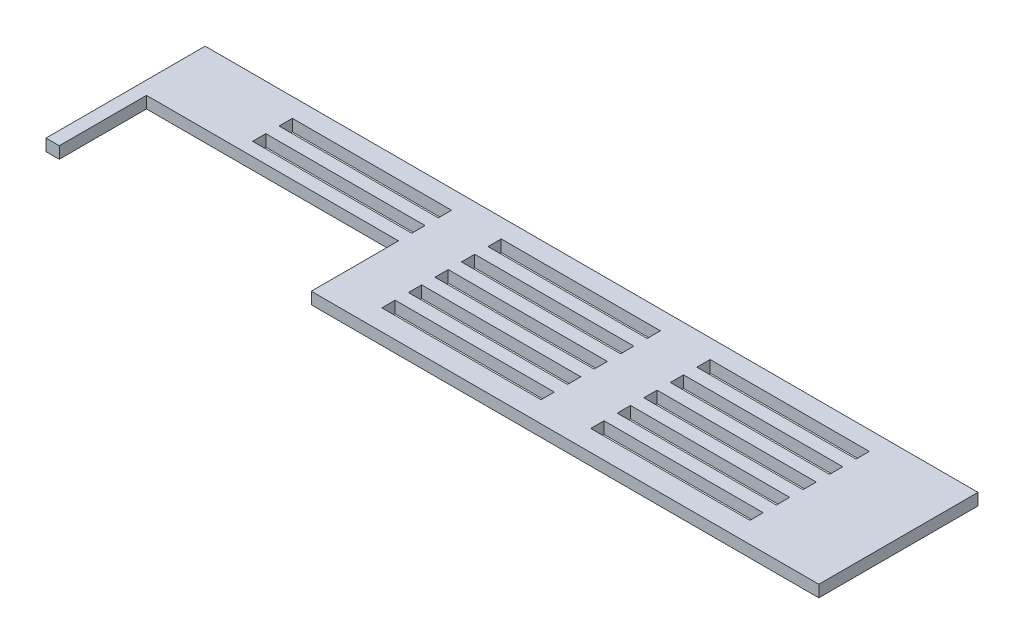
from build123d import *

# Parameters (mm, degrees)
BOSS_EXTRUDE1_DEPTH  = 5.6388
SKETCH2_W            = 76.2
SKETCH2_H            = 6.35
CUT_EXTRUDE1_DEPTH   = 6.6388
LPATTERN1_COUNT      = 5
LPATTERN1_PITCH      = 12.7
LPATTERN1_COUNT_DIR2 = 3
LPATTERN1_PITCH_DIR2 = 100
SKETCH3_W            = 120.65
SKETCH3_H            = 41.75
CUT_EXTRUDE2_DEPTH   = 6.6388


with BuildPart() as part:
    # Sketch1 → Boss-Extrude1 (new body)
    with BuildSketch(Plane(origin=(0, 0, 0), x_dir=(1, 0, 0), z_dir=(0, 1, 0))):
        Polygon((-185, -73.025), (185, -73.025), (185, -6.825), (185, 3.175), (175, 3.175), (-175, 3.175), (-185, 3.175), (-185, -6.825), align=None)
    extrude(amount=BOSS_EXTRUDE1_DEPTH)

    # Sketch2 → Cut-Extrude1 (cut, through all)
    with BuildSketch(Plane(origin=(0, 5.6388, 0), x_dir=(1, 0, 0), z_dir=(0, 1, 0))):
        with Locations((-96.1, -59.85)):
            Rectangle(SKETCH2_W, SKETCH2_H)
    cut_extrude1 = extrude(amount=-CUT_EXTRUDE1_DEPTH, mode=Mode.SUBTRACT)

    # LPattern1: Cut-Extrude1 5 × 3
    with Locations(*[(j * LPATTERN1_PITCH_DIR2, 0, -i * LPATTERN1_PITCH) for i in range(LPATTERN1_COUNT) for j in range(LPATTERN1_COUNT_DIR2) if (i, j) != (0, 0)]):
        add(cut_extrude1, mode=Mode.SUBTRACT)

    # Sketch3 → Cut-Extrude2 (cut, through all)
    with BuildSketch(Plane(origin=(0, 5.6388, 0), x_dir=(1, 0, 0), z_dir=(0, 1, 0))):
        with Locations((-118.325, -52.15)):
            Rectangle(SKETCH3_W, SKETCH3_H)
    extrude(amount=-CUT_EXTRUDE2_DEPTH, mode=Mode.SUBTRACT)


solid = part.part
